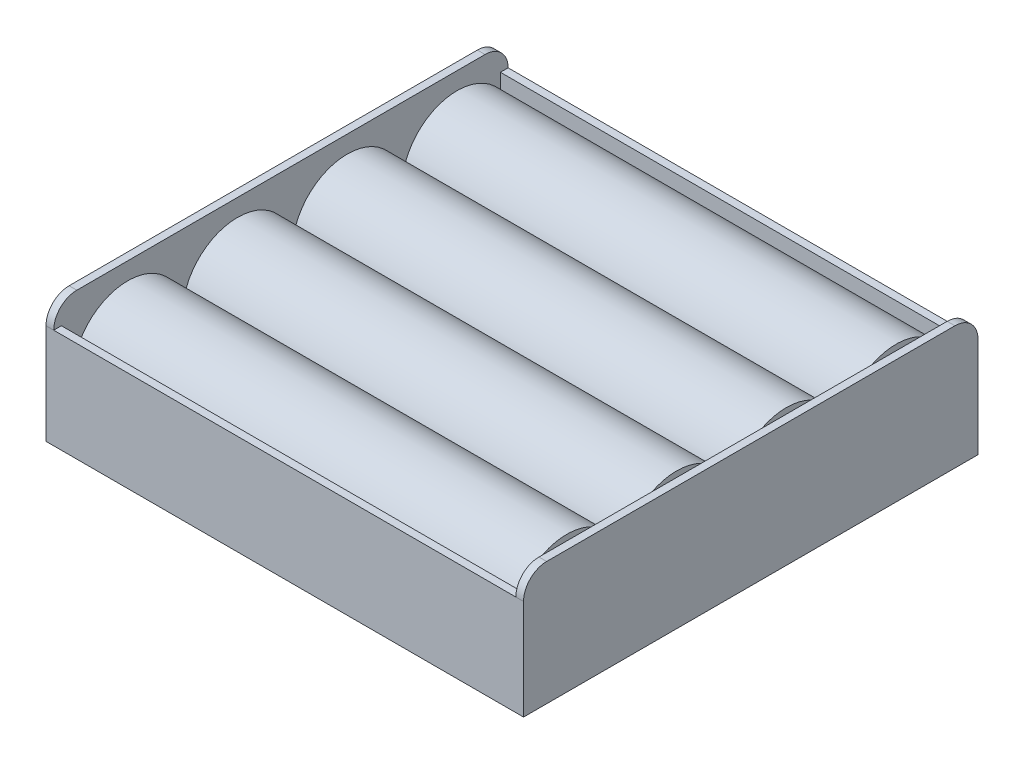
from build123d import *

# Parameters (mm, degrees)
LINEAR_AUSTRAGEN1_DEPTH   = 30
LINEAR_AUSTRAGEN2_DEPTH   = 1
LINEAR_AUSTRAGEN3_DEPTH   = 28.5
SKIZZE3_R                 = 7.125
LINEAR_AUSTRAGEN3_2_DEPTH = 28.5
LINEAR_AUSTRAGEN3_3_DEPTH = 28.5
LINEAR_AUSTRAGEN3_4_DEPTH = 28.5


with BuildPart() as part:
    # Skizze1 → Linear austragen1 (new body)
    with BuildSketch(Plane(origin=(0, 0, 0), x_dir=(0, 0, -1), z_dir=(1, 0, 0))):
        Polygon((29.5, 13), (29.5, 0), (-29.5, 0), (-29.5, 13), (-28.5, 13), (-28.5, 1), (28.5, 1), (28.5, 13), align=None)
    linear_austragen1 = extrude(amount=LINEAR_AUSTRAGEN1_DEPTH)

    # Skizze2 → Linear austragen2 (add)
    with BuildSketch(Plane(origin=(30, 0, 0), x_dir=(0, 0, -1), z_dir=(1, 0, 0))):
        with BuildLine():
            Line((-29.5, 0), (29.5, 0))
            Line((29.5, 0), (29.5, 13))
            ThreePointArc((29.5, 13), (28.621320344, 15.121320344), (26.5, 16))
            Line((26.5, 16), (-26.5, 16))
            ThreePointArc((-26.5, 16), (-28.621320344, 15.121320344), (-29.5, 13))
            Line((-29.5, 13), (-29.5, 0))
        make_face()
    linear_austragen2 = extrude(amount=LINEAR_AUSTRAGEN2_DEPTH)

    # Spiegeln11: Linear austragen1, Linear austragen2 across plane
    add(linear_austragen1.mirror(Plane(origin=(0, 13, -29.5), x_dir=(0, 0, 1), z_dir=(-1, 0, 0))))
    add(linear_austragen2.mirror(Plane(origin=(0, 13, -29.5), x_dir=(0, 0, 1), z_dir=(-1, 0, 0))))


with BuildPart() as body_2:
    # Skizze3 → Linear austragen3 (new, symmetric)
    with BuildSketch(Plane(origin=(0, 0, 0), x_dir=(0, 0, -1), z_dir=(1, 0, 0))):
        with BuildLine():
            ThreePointArc((0, 8.125), (-7.125, 15.25), (-14.25, 8.125))
            Line((-14.25, 8.125), (0, 8.125))
        make_face()
    extrude(amount=LINEAR_AUSTRAGEN3_DEPTH, both=True)


with BuildPart() as body_3:
    # Skizze3 → Linear austragen3 2 (new, symmetric)
    with BuildSketch(Plane(origin=(0, 0, 0), x_dir=(0, 0, -1), z_dir=(1, 0, 0))):
        with Locations(Location((-21.375, 8.125, 0), (0, 0, 180))):
            Circle(SKIZZE3_R)
    extrude(amount=LINEAR_AUSTRAGEN3_2_DEPTH, both=True)


with BuildPart() as body_4:
    # Skizze3 → Linear austragen3 3 (new, symmetric)
    with BuildSketch(Plane(origin=(0, 0, 0), x_dir=(0, 0, -1), z_dir=(1, 0, 0))):
        with Locations(Location((21.375, 8.125, 0), (0, 0, 180))):
            Circle(SKIZZE3_R)
    extrude(amount=LINEAR_AUSTRAGEN3_3_DEPTH, both=True)


with BuildPart() as body_5:
    # Skizze3 → Linear austragen3 4 (new, symmetric)
    with BuildSketch(Plane(origin=(0, 0, 0), x_dir=(0, 0, -1), z_dir=(1, 0, 0))):
        with BuildLine():
            ThreePointArc((14.25, 8.125), (7.125, 15.25), (0, 8.125))
            Line((0, 8.125), (14.25, 8.125))
        make_face()
    extrude(amount=LINEAR_AUSTRAGEN3_4_DEPTH, both=True)


solid = Compound([part.part, body_2.part, body_3.part, body_4.part, body_5.part])
